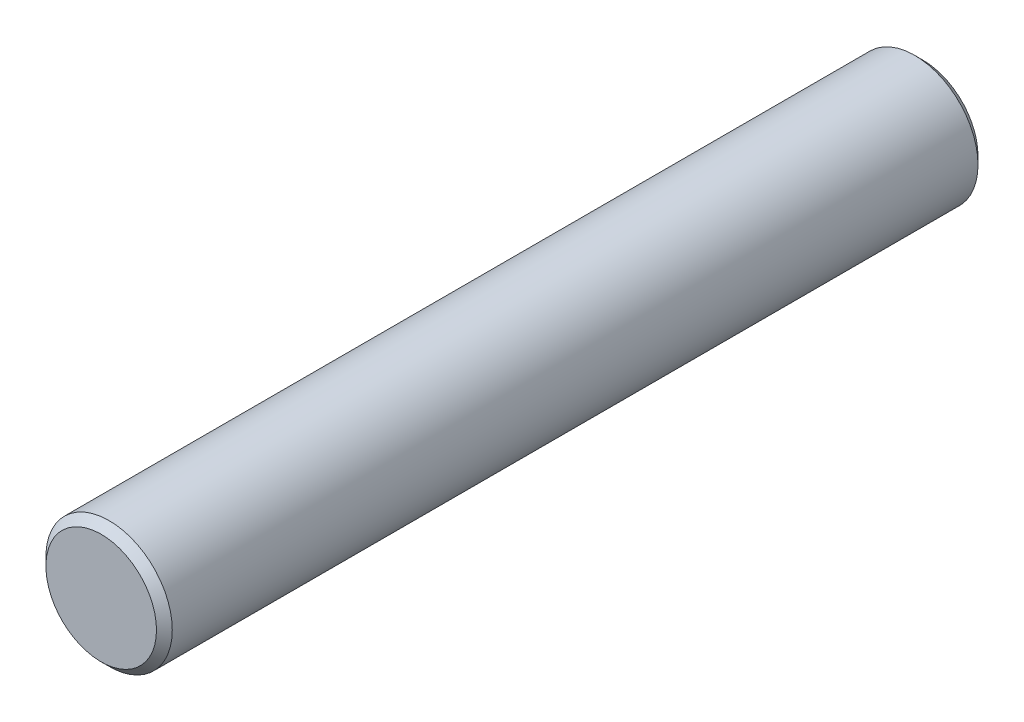
from build123d import *

# Parameters (mm, degrees)
SKETCH_1_R      = 4
EXTRUDE_1_DEPTH = 52
CHAMFER_1_SIZE  = 0.5


with BuildPart() as part:
    # Эскиз1 → Вытянуть1 (new body)
    with BuildSketch(Plane.XY):
        Circle(SKETCH_1_R)
    extrude(amount=EXTRUDE_1_DEPTH)

    # Фаска1
    chamfer_1_edges = [part.edges().sort_by_distance(p)[0] for p in [
        (-4, 0, 0),
        (-4, 0, 52),
    ]]
    chamfer(chamfer_1_edges, length=CHAMFER_1_SIZE)


solid = part.part
